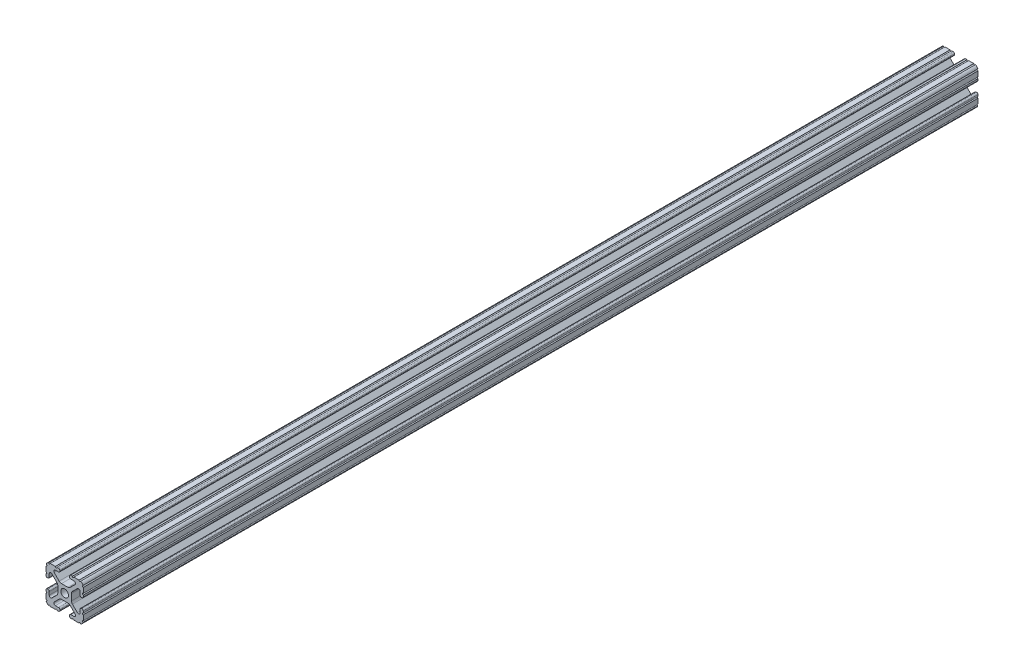
from build123d import *

# Parameters (mm, degrees)
BOSS_EXTRUDE1_DEPTH     = 304.8
SKETCH5_R               = 0.55245
CUT_EXTRUDE1_DEPTH      = 305.8
CUT_EXTRUDE1_DEPTH_BACK = 305.8


with BuildPart() as part:
    # Sketch4 → Boss-Extrude1 (new body, symmetric)
    with BuildSketch(Plane.XY):
        with BuildLine():
            Line((4.190365, -12.7), (10.11729625, -12.7))
            ThreePointArc((10.11729625, -12.7), (11.943543585, -11.943543585), (12.7, -10.11729625))
            Line((12.7, -10.11729625), (12.7, -4.190365))
            ThreePointArc((12.7, -4.190365), (12.42492494, -3.52627506), (11.760835, -3.2512))
            Line((11.760835, -3.2512), (11.429365, -3.2512))
            ThreePointArc((11.429365, -3.2512), (10.76527506, -3.52627506), (10.4902, -4.190365))
            Line((10.4902, -4.190365), (10.4902, -6.348478019))
            ThreePointArc((10.4902, -6.348478019), (9.830707141, -7.335478831), (8.666460301, -7.103895736))
            Line((8.666460301, -7.103895736), (5.299899128, -3.737334563))
            ThreePointArc((5.299899128, -3.737334563), (4.817571085, -3.015479634), (4.6482, -2.16399369))
            Line((4.6482, -2.16399369), (4.6482, 0))
            Line((4.6482, 0), (2.6035, 0))
            ThreePointArc((2.6035, 0), (1.840952505, -1.840952505), (0, -2.6035))
            Line((0, -2.6035), (0, -4.6482))
            Line((0, -4.6482), (2.16399369, -4.6482))
            ThreePointArc((2.16399369, -4.6482), (3.015479634, -4.817571085), (3.737334563, -5.299899128))
            Line((3.737334563, -5.299899128), (7.103895736, -8.666460301))
            ThreePointArc((7.103895736, -8.666460301), (7.335478831, -9.830707141), (6.348478019, -10.4902))
            Line((6.348478019, -10.4902), (4.190365, -10.4902))
            ThreePointArc((4.190365, -10.4902), (3.52627506, -10.76527506), (3.2512, -11.429365))
            Line((3.2512, -11.429365), (3.2512, -11.760835))
            ThreePointArc((3.2512, -11.760835), (3.52627506, -12.42492494), (4.190365, -12.7))
        make_face()
    extrude(amount=BOSS_EXTRUDE1_DEPTH, both=True)

    # Sketch5 → Cut-Extrude1 (cut, two sides)
    with BuildSketch(Plane.XY) as cut_extrude1_sk:
        with Locations((10.356153152, -12.7)):
            Circle(SKETCH5_R)
        with Locations((5.796028019, -12.7)):
            Circle(SKETCH5_R)
        with Locations((12.7, -10.356153152)):
            Circle(SKETCH5_R)
        with Locations((12.7, -5.796028019)):
            Circle(SKETCH5_R)
    extrude(amount=CUT_EXTRUDE1_DEPTH, mode=Mode.SUBTRACT)
    extrude(cut_extrude1_sk.sketch, amount=-CUT_EXTRUDE1_DEPTH_BACK, mode=Mode.SUBTRACT)

    # Mirror1: part across plane


with BuildPart() as part_1:
    add(part.part)
    add(part.part.mirror(Plane(origin=(0, 0, 0), x_dir=(0, 0, 1), z_dir=(1, 0, 0))))

    # Mirror2: part across plane


with BuildPart() as part_2:
    add(part_1.part)
    add(part_1.part.mirror(Plane.ZX))


solid = part_2.part
